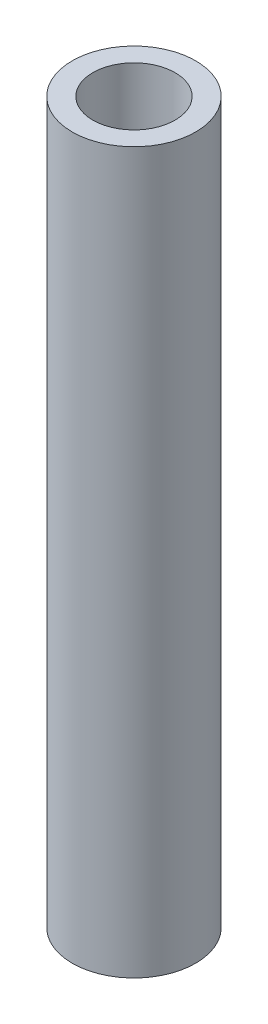
from build123d import *

# Parameters (mm, degrees)
SKETCH1_R           = 3
SKETCH1_R_2         = 2
BOSS_EXTRUDE1_DEPTH = 35


with BuildPart() as part:
    # Sketch1 → Boss-Extrude1 (new body)
    with BuildSketch(Plane(origin=(0, 0, 0), x_dir=(1, 0, 0), z_dir=(0, 1, 0))):
        Circle(SKETCH1_R)
        Circle(SKETCH1_R_2, mode=Mode.SUBTRACT)
    extrude(amount=BOSS_EXTRUDE1_DEPTH)


solid = part.part
